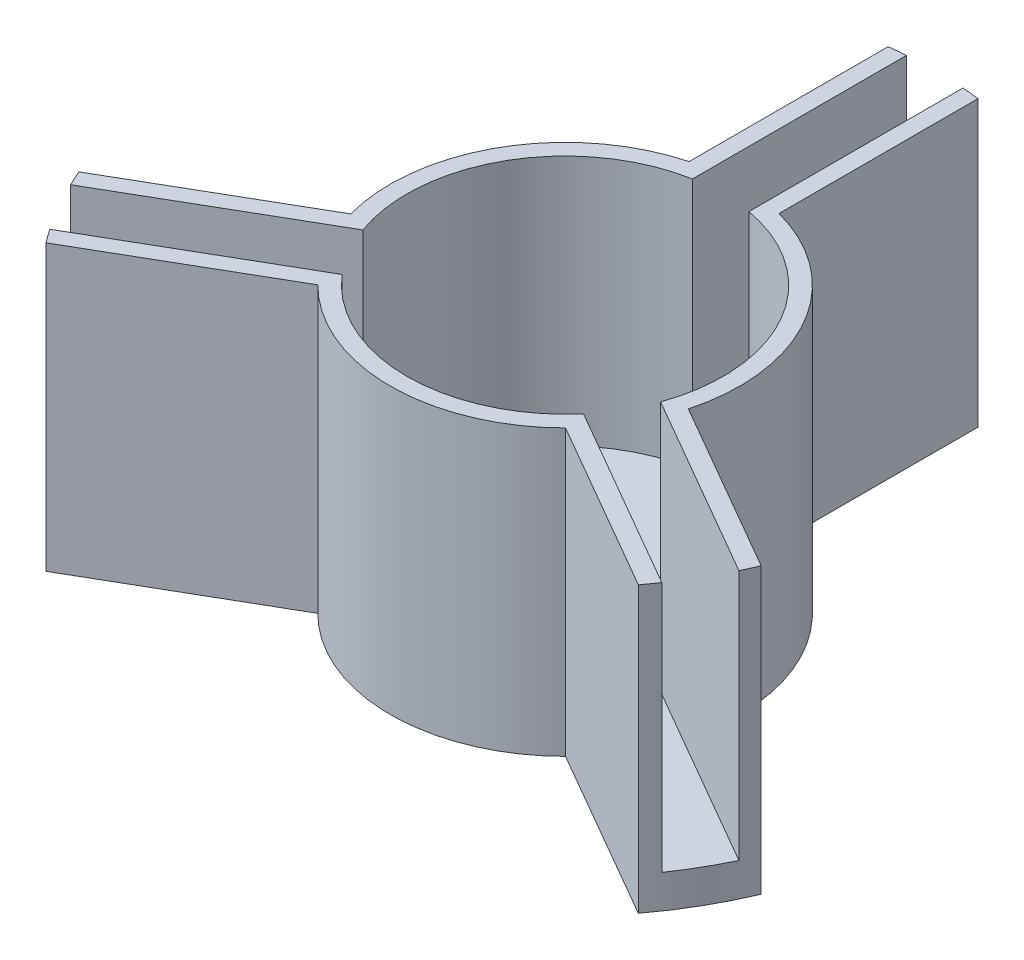
from build123d import *

# Parameters (mm, degrees)
SKETCH2_R           = 22.15
SKETCH2_R_2         = 9.45
BOSS_EXTRUDE2_DEPTH = 15
SKETCH3_R           = 22.15
BOSS_EXTRUDE3_DEPTH = 2
CUT_EXTRUDE1_DEPTH  = 15
CIRPATTERN1_COUNT   = 3
CUT_EXTRUDE2_DEPTH  = 17
CIRPATTERN2_COUNT   = 3


with BuildPart() as part:
    # Sketch2 → Boss-Extrude2 (new body)
    with BuildSketch(Plane(origin=(0, 0, 0), x_dir=(1, 0, 0), z_dir=(0, 1, 0))):
        Circle(SKETCH2_R)
        Circle(SKETCH2_R_2, mode=Mode.SUBTRACT)
    extrude(amount=BOSS_EXTRUDE2_DEPTH)

    # Sketch3 → Boss-Extrude3 (add)
    with BuildSketch(Plane.XZ):
        Circle(SKETCH3_R)
    extrude(amount=BOSS_EXTRUDE3_DEPTH)

    # Sketch4 → Cut-Extrude1 (cut)
    with BuildSketch(Plane(origin=(0, 15, 0), x_dir=(1, 0, 0), z_dir=(0, 1, 0))):
        with BuildLine():
            Line((-1.6875, 22.085625274), (-1.6875, 9.298109687))
            ThreePointArc((-1.6875, 9.298109687), (0, 9.45), (1.6875, 9.298109687))
            Line((1.6875, 9.298109687), (1.6875, 22.085625274))
            ThreePointArc((1.6875, 22.085625274), (0, 22.15), (-1.6875, 22.085625274))
        make_face()
    cut_extrude1 = extrude(amount=-CUT_EXTRUDE1_DEPTH, mode=Mode.SUBTRACT)

    # CirPattern1: Cut-Extrude1 ×3 about axis
    cirpattern1_axis = Axis((0, 0, 0), (0, 1, 0))
    for i in range(1, CIRPATTERN1_COUNT):
        add(cut_extrude1.rotate(cirpattern1_axis, i * 360 / CIRPATTERN1_COUNT), mode=Mode.SUBTRACT)

    # Sketch6 → Cut-Extrude2 (cut)
    with BuildSketch(Plane(origin=(0, 15, 0), x_dir=(1, 0, 0), z_dir=(0, 1, 0))):
        with BuildLine():
            Line((-20.384492706, -8.665734654), (-10.089313607, -2.72181023))
            ThreePointArc((-10.089313607, -2.72181023), (-9.04996547, 5.225), (-2.6875, 10.098507006))
            Line((-2.6875, 10.098507006), (-2.6875, 21.986355854))
            ThreePointArc((-2.6875, 21.986355854), (-19.182462694, 11.075), (-20.384492706, -8.665734654))
        make_face()
    cut_extrude2 = extrude(amount=-CUT_EXTRUDE2_DEPTH, mode=Mode.SUBTRACT)

    # CirPattern2: Cut-Extrude2 ×3 about axis
    cirpattern2_axis = Axis((0, 0, 0), (0, 1, 0))
    for i in range(1, CIRPATTERN2_COUNT):
        add(cut_extrude2.rotate(cirpattern2_axis, i * 360 / CIRPATTERN2_COUNT), mode=Mode.SUBTRACT)


solid = part.part
